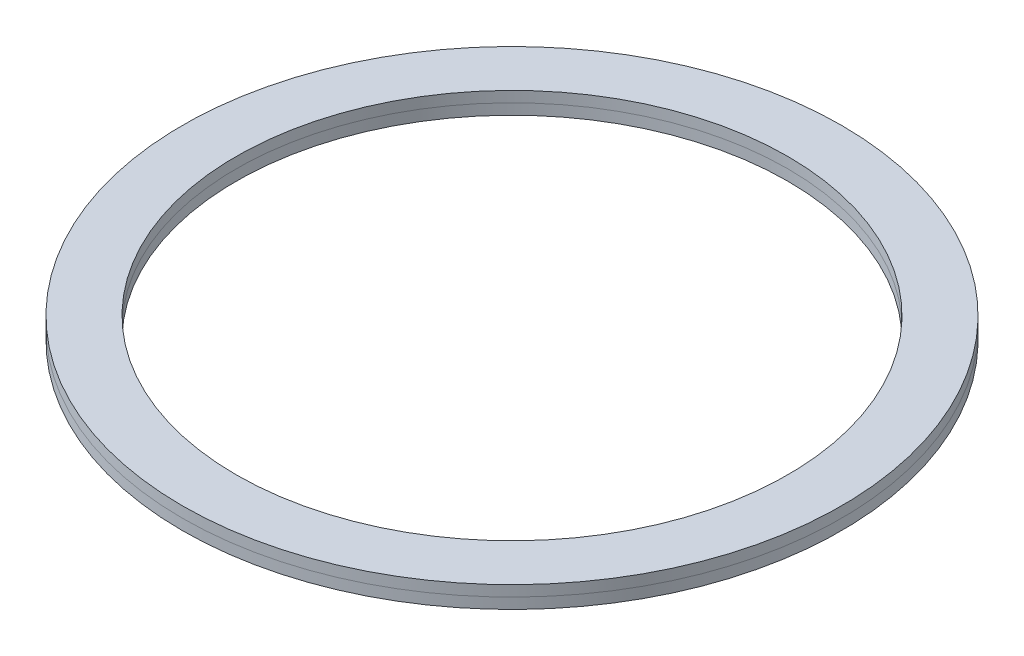
from build123d import *

# Parameters (mm, degrees)
SKETCH1_W = 5
SKETCH1_H = 2


with BuildPart() as part:
    # Sketch1 → Revolve1 (revolve)
    with BuildSketch(Plane.XY):
        with Locations((-28.15, 1)):
            Rectangle(SKETCH1_W, SKETCH1_H)
    revolve(axis=Axis((0, 0, 0), (0, 1, 0)))


with BuildPart() as body_2:
    # Split1: the piece on the far side of the plane
    add(part.part)
    split(bisect_by=Plane.ZX.offset(1), keep=Keep.BOTTOM)


with BuildPart() as part_1:
    add(part.part)

    # Split1
    split(bisect_by=Plane.ZX.offset(1), keep=Keep.TOP)


solid = Compound([body_2.part, part_1.part])
